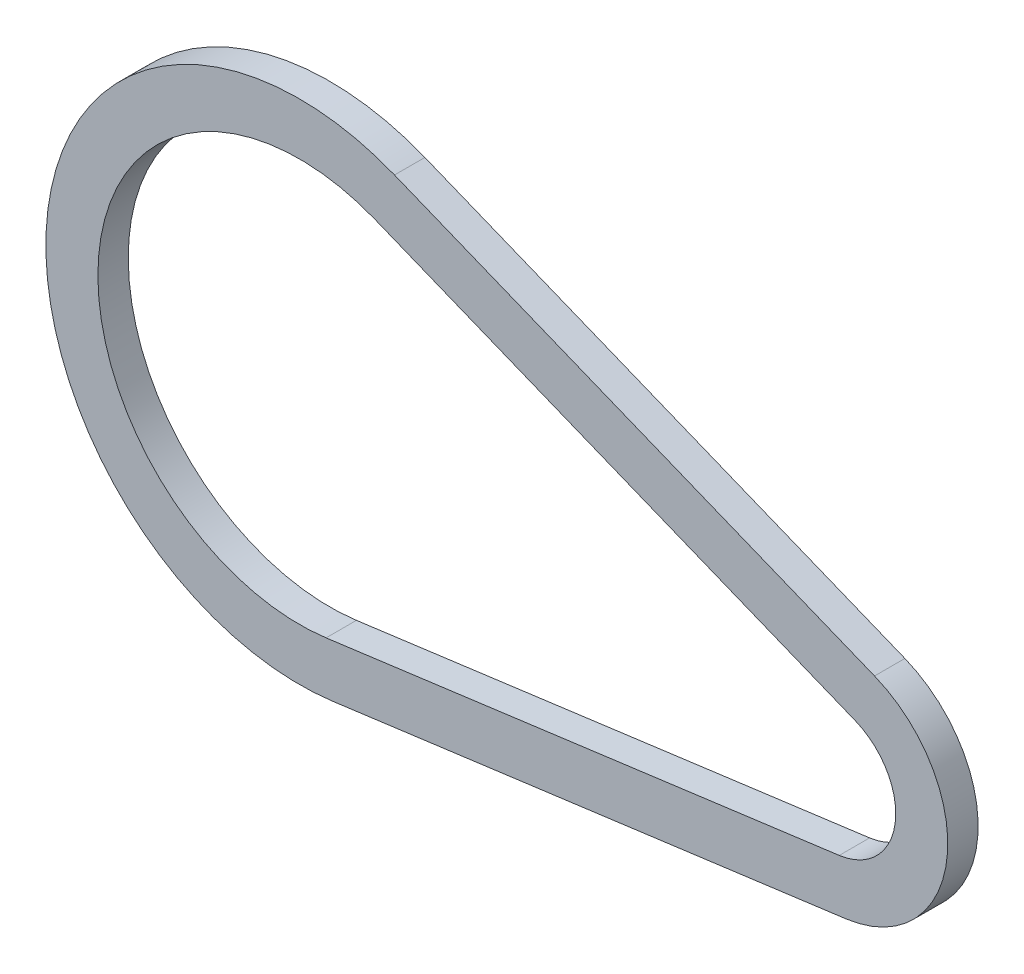
from build123d import *

# Parameters (mm, degrees)
BOSS_EXTRUDE1_DEPTH = 3.5


with BuildPart() as part:
    # Sketch1 → Boss-Extrude1 (new body, symmetric)
    with BuildSketch(Plane.XY):
        with BuildLine():
            Line((-100.593673118, 69.743551161), (10.110612407, 25.035485151))
            ThreePointArc((10.110612407, 25.035485151), (26.786426149, -3.389302901), (3.556294752, -26.764767282))
            Line((3.556294752, -26.764767282), (-114.794694704, -42.49032911))
            ThreePointArc((-114.794694704, -42.49032911), (-180.537256657, 22.843489618), (-100.593673118, 69.743551161))
        make_face()
        with BuildLine():
            Line((-105.087278633, 58.616668872), (5.617006893, 13.908602862))
            ThreePointArc((5.617006893, 13.908602862), (14.881347861, -1.882946056), (1.975719307, -14.869315156))
            Line((1.975719307, -14.869315156), (-116.375270149, -30.594876985))
            ThreePointArc((-116.375270149, -30.594876985), (-168.632178368, 21.337132773), (-105.087278633, 58.616668872))
        make_face(mode=Mode.SUBTRACT)
    extrude(amount=BOSS_EXTRUDE1_DEPTH, both=True)


solid = part.part
